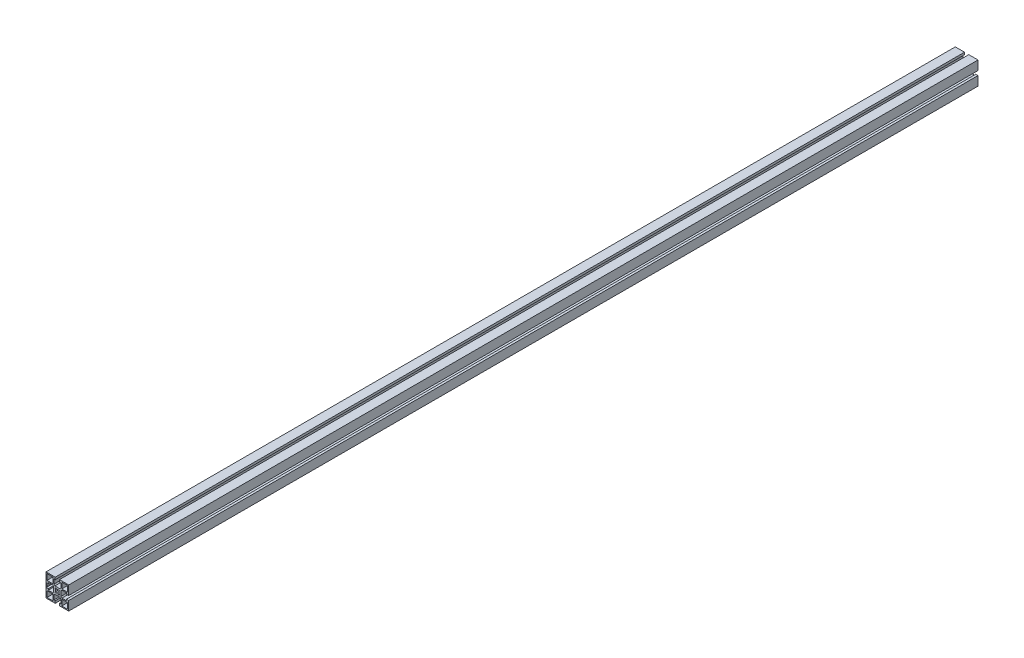
from build123d import *

# Parameters (mm, degrees)
SKETCH1_W           = 11.699975178
SKETCH1_H           = 11.699996949
SKETCH1_W_2         = 11.699990436
SKETCH1_H_2         = 11.699981689
SKETCH1_W_3         = 11.699990437
SKETCH1_H_3         = 11.699975177
SKETCH1_W_4         = 11.699981689
SKETCH1_H_4         = 11.699990436
BOSS_EXTRUDE1_DEPTH = 1803.4
CUT_EXTRUDE1_REACH  = 1805.681


with BuildPart() as part:
    # Sketch1 → Boss-Extrude1 (new body)
    with BuildSketch(Plane.XY):
        Polygon((22.500515052, 22.499297556), (-22.499484399, 22.499298105), (-22.499484948, -22.500701346), (-4.249491942, -22.500701568), (-4.249491942, -22.200733242), (-4.24949208, -18.000719999), (-6.799479919, -18.000719999), (-6.799480207, -9.200732353), (-4.799480391, -7.200732362), (4.800525817, -7.200732047), (6.8005258, -9.200731855), (6.800526088, -18.000720263), (4.250507877, -18.000720263), (4.250508015, -22.200733153), (4.250508015, -22.500701672), (22.500514502, -22.500701895), (22.500514725, -4.250714302), (22.200520351, -4.250714302), (18.000507108, -4.25071444), (18.000507108, -6.800702279), (9.200519462, -6.800702567), (7.200519471, -4.800702751), (7.200519156, 4.799303458), (9.200518964, 6.79930344), (18.000507424, 6.799303729), (18.000507424, 4.249285514), (22.200520261, 4.249285652), (22.500514829, 4.249285652), align=None)
        with BuildLine():
            Line((-4.249491247, 17.999291576), (-4.249490956, 22.199304807))
            Line((-4.249490956, 22.199304807), (-3.949472548, 22.199304807))
            Line((-3.949472548, 22.199304807), (-3.481695222, 21.73152644))
            ThreePointArc((-3.481695222, 21.73152644), (-2.670636178, 21.189593132), (-1.713926324, 20.999291428))
            Line((-1.713926324, 20.999291428), (1.714975167, 20.999291428))
            ThreePointArc((1.714975167, 20.999291428), (2.671722509, 21.189608628), (3.482801459, 21.731583767))
            Line((3.482801459, 21.731583767), (3.950490798, 22.199304487))
            Line((3.950490798, 22.199304487), (4.250509108, 22.199304487))
            Line((4.250509108, 22.199304487), (4.250508817, 17.999291575))
            Line((4.250508817, 17.999291575), (6.800527063, 17.999291575))
            Line((6.800527063, 17.999291575), (6.800526453, 9.199302988))
            Line((6.800526453, 9.199302988), (4.800526064, 7.199302969))
            Line((4.800526064, 7.199302969), (-4.799479817, 7.199303635))
            Line((-4.799479817, 7.199303635), (-6.799479854, 9.199304042))
            Line((-6.799479854, 9.199304042), (-6.799479244, 17.999291576))
            Line((-6.799479244, 17.999291576), (-4.249491247, 17.999291576))
        make_face(mode=Mode.SUBTRACT)
        with BuildLine():
            Line((-17.99949762, -4.250714253), (-22.199510799, -4.250714391))
            Line((-22.199510799, -4.250714391), (-22.199510799, -3.950696126))
            Line((-22.199510799, -3.950696126), (-21.731790056, -3.48300681))
            ThreePointArc((-21.731790056, -3.48300681), (-21.189814855, -2.671927844), (-20.999497617, -1.71518046))
            Line((-20.999497617, -1.71518046), (-20.999497617, 1.713721031))
            ThreePointArc((-20.999497617, 1.713721031), (-21.189799286, 2.670430863), (-21.731732544, 3.481489907))
            Line((-21.731732544, 3.481489907), (-22.199510888, 3.949267256))
            Line((-22.199510888, 3.949267256), (-22.199510888, 4.249285566))
            Line((-22.199510888, 4.249285566), (-17.999497356, 4.249285704))
            Line((-17.999497356, 4.249285704), (-17.999497356, 6.79927354))
            Line((-17.999497356, 6.79927354), (-9.199509947, 6.799273828))
            Line((-9.199509947, 6.799273828), (-7.199509956, 4.799274012))
            Line((-7.199509956, 4.799274012), (-7.199509641, -4.800732197))
            Line((-7.199509641, -4.800732197), (-9.199509449, -6.800732179))
            Line((-9.199509449, -6.800732179), (-17.99949762, -6.800732468))
            Line((-17.99949762, -6.800732468), (-17.99949762, -4.250714253))
        make_face(mode=Mode.SUBTRACT)
        with Locations((-14.649542346, -14.650709384)):
            Rectangle(SKETCH1_W, SKETCH1_H, mode=Mode.SUBTRACT)
        with Locations((14.65050626, -14.650767962)):
            Rectangle(SKETCH1_W_2, SKETCH1_H_2, mode=Mode.SUBTRACT)
        with BuildLine():
            Line((-3.181457266, -4.596908447), (-4.595670829, -3.182694885))
            Line((-4.595670829, -3.182694885), (-3.26221457, -1.849238626))
            ThreePointArc((-3.26221457, -1.849238626), (-3.749476751, -0.00071437), (-3.26221457, 1.847809887))
            Line((-3.26221457, 1.847809887), (-4.595670829, 3.181266146))
            Line((-4.595670829, 3.181266146), (-3.181457266, 4.595479708))
            Line((-3.181457266, 4.595479708), (-1.848001007, 3.262023449))
            ThreePointArc((-1.848001007, 3.262023449), (0.000523249, 3.74928563), (1.849047505, 3.262023449))
            Line((1.849047505, 3.262023449), (3.182503764, 4.595479708))
            Line((3.182503764, 4.595479708), (4.596717327, 3.181266146))
            Line((4.596717327, 3.181266146), (3.263261068, 1.847809887))
            ThreePointArc((3.263261068, 1.847809887), (3.750523249, -0.00071437), (3.263261068, -1.849238626))
            Line((3.263261068, -1.849238626), (4.596717327, -3.182694885))
            Line((4.596717327, -3.182694885), (3.182503764, -4.596908447))
            Line((3.182503764, -4.596908447), (1.849047505, -3.263452188))
            ThreePointArc((1.849047505, -3.263452188), (0.000523249, -3.75071437), (-1.848001007, -3.263452188))
            Line((-1.848001007, -3.263452188), (-3.181457266, -4.596908447))
        make_face(mode=Mode.SUBTRACT)
        with Locations((-14.64949028, 14.649335967)):
            Rectangle(SKETCH1_W_3, SKETCH1_H_3, mode=Mode.SUBTRACT)
        with Locations((14.650561583, 14.6492839)):
            Rectangle(SKETCH1_W_4, SKETCH1_H_4, mode=Mode.SUBTRACT)
    extrude(amount=BOSS_EXTRUDE1_DEPTH)

    # Sketch1_4 → Cut-Extrude1 (cut, up to next)
    with BuildSketch(Plane.XY, mode=Mode.PRIVATE) as cut_extrude1_sk1:
        with BuildLine():
            Line((-4.249490956, 22.499297883), (-4.249490956, 22.199304807))
            Line((-4.249490956, 22.199304807), (-3.949472548, 22.199304807))
            Line((-3.949472548, 22.199304807), (-3.481695222, 21.73152644))
            ThreePointArc((-3.481695222, 21.73152644), (-2.670636178, 21.189593132), (-1.713926324, 20.999291428))
            Line((-1.713926324, 20.999291428), (1.714975167, 20.999291428))
            ThreePointArc((1.714975167, 20.999291428), (2.671722509, 21.189608628), (3.482801459, 21.731583767))
            Line((3.482801459, 21.731583767), (3.950490798, 22.199304487))
            Line((3.950490798, 22.199304487), (4.250509108, 22.199304487))
            Line((4.250509108, 22.199304487), (4.250509108, 22.499297779))
            Line((4.250509108, 22.499297779), (-4.249490956, 22.499297883))
        make_face()
    cut_extrude1_tool1 = extrude(cut_extrude1_sk1.sketch, amount=CUT_EXTRUDE1_REACH, mode=Mode.PRIVATE) & part.part
    add(cut_extrude1_tool1.solids().sort_by_distance((0.000518, 21.824215, 0))[0], mode=Mode.SUBTRACT)


solid = part.part
